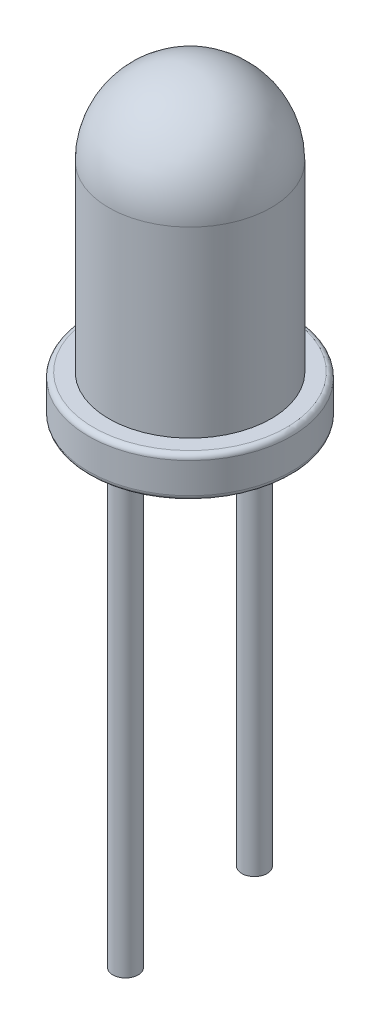
from build123d import *

# Parameters (mm, degrees)
FILLET1_R           = 0.1
SKETCH2_R           = 0.25
BOSS_EXTRUDE1_DEPTH = 10
SKETCH3_R           = 0.25
BOSS_EXTRUDE2_DEPTH = 7


with BuildPart() as part:
    # Sketch1 one side → Revolve6 (revolve)
    with BuildSketch(Plane.XY):
        with BuildLine():
            Line((0, 0), (2, 0))
            Line((2, 0), (2, 0.8))
            Line((2, 0.8), (1.6, 0.8))
            Line((1.6, 0.8), (1.6, 4.4))
            ThreePointArc((1.6, 4.4), (1.13137085, 5.53137085), (0, 6))
            Line((0, 6), (0, 0))
        make_face()
    revolve(axis=Axis((0, 8.598320721, 0), (0, -1, 0)))

    # Fillet1
    fillet1_edges = [part.edges().sort_by_distance(p)[0] for p in [
        (-2, 0, 0),
        (-2, 0.8, 0),
    ]]
    fillet(fillet1_edges, radius=FILLET1_R)

    # Sketch2 → Boss-Extrude1 (add)
    with BuildSketch(Plane.XZ):
        with Locations((-1.27, 0)):
            Circle(SKETCH2_R)
    extrude(amount=BOSS_EXTRUDE1_DEPTH)

    # Sketch3 → Boss-Extrude2 (add)
    with BuildSketch(Plane.XZ):
        with Locations((1.27, 0)):
            Circle(SKETCH3_R)
    extrude(amount=BOSS_EXTRUDE2_DEPTH)


solid = part.part
